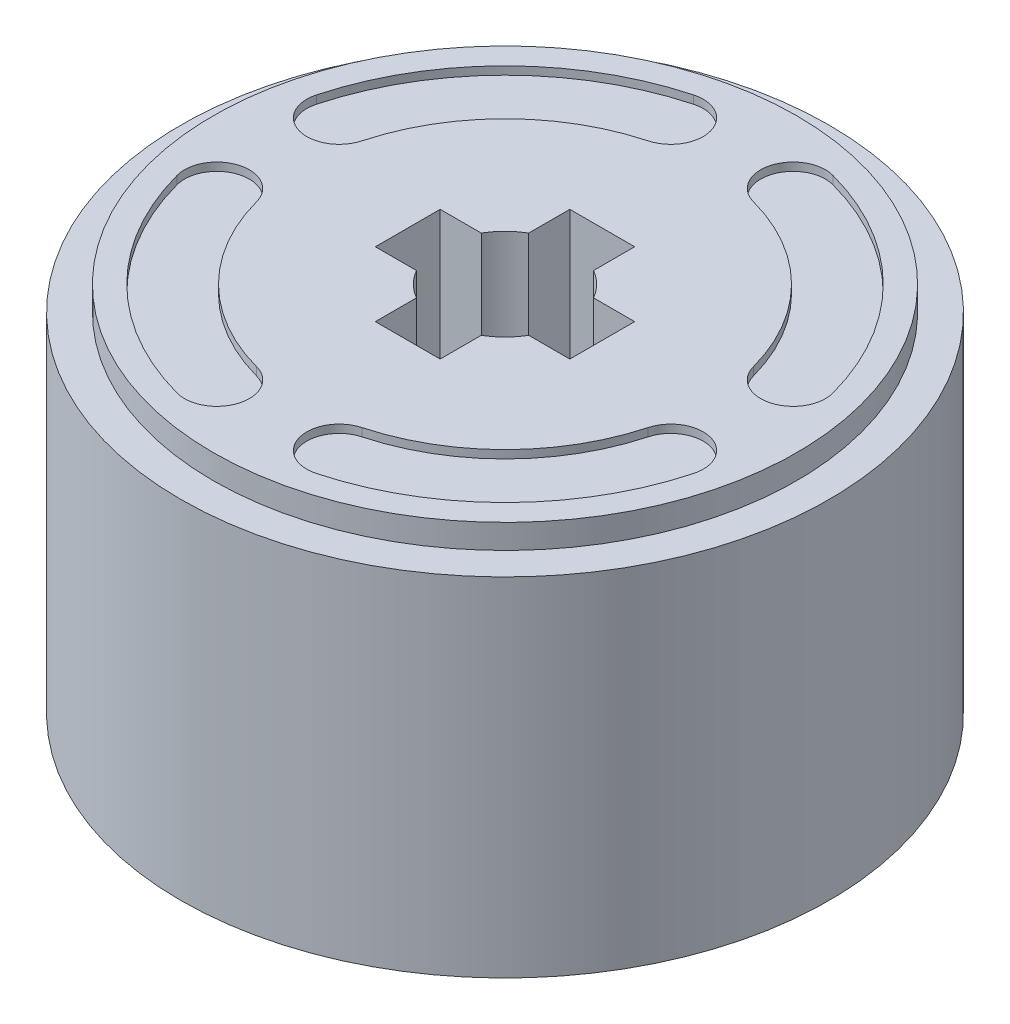
from build123d import *

# Parameters (mm, degrees)
SKETCH1_R           = 14
BOSS_EXTRUDE2_DEPTH = 16.05
CUT_EXTRUDE1_START  = -1.05
SKETCH3_R           = 14
SKETCH3_R_2         = 12.6
CUT_EXTRUDE1_DEPTH  = 1.05
CUT_EXTRUDE2_DEPTH  = 0.35


with BuildPart() as part:
    # Sketch1 → Boss-Extrude2 (new body)
    with BuildSketch(Plane(origin=(0, 0, 0), x_dir=(1, 0, 0), z_dir=(0, 1, 0))):
        Circle(SKETCH1_R)
        with BuildLine():
            Line((-1.4, 4.2), (-1.4, 2.424871131))
            ThreePointArc((-1.4, 2.424871131), (-1.979898987, 1.979898987), (-2.424871131, 1.4))
            Line((-2.424871131, 1.4), (-4.2, 1.4))
            Line((-4.2, 1.4), (-4.2, -1.4))
            Line((-4.2, -1.4), (-2.424871131, -1.4))
            ThreePointArc((-2.424871131, -1.4), (-1.979898987, -1.979898987), (-1.4, -2.424871131))
            Line((-1.4, -2.424871131), (-1.4, -4.2))
            Line((-1.4, -4.2), (1.4, -4.2))
            Line((1.4, -4.2), (1.4, -2.424871131))
            ThreePointArc((1.4, -2.424871131), (1.979898987, -1.979898987), (2.424871131, -1.4))
            Line((2.424871131, -1.4), (4.2, -1.4))
            Line((4.2, -1.4), (4.2, 1.4))
            Line((4.2, 1.4), (2.424871131, 1.4))
            ThreePointArc((2.424871131, 1.4), (1.979898987, 1.979898987), (1.4, 2.424871131))
            Line((1.4, 2.424871131), (1.4, 4.2))
            Line((1.4, 4.2), (-1.4, 4.2))
        make_face(mode=Mode.SUBTRACT)
    extrude(amount=BOSS_EXTRUDE2_DEPTH)

    # Sketch3 → Cut-Extrude1 (cut)
    with BuildSketch(Plane(origin=(0, 16.05, 0), x_dir=(1, 0, 0), z_dir=(0, 1, 0)).offset(CUT_EXTRUDE1_START)):
        Circle(SKETCH3_R)
        Circle(SKETCH3_R_2, mode=Mode.SUBTRACT)
    extrude(amount=CUT_EXTRUDE1_DEPTH, mode=Mode.SUBTRACT)

    # Sketch3_3 → Cut-Extrude2 (cut)
    with BuildSketch(Plane(origin=(0, 16.05, 0), x_dir=(1, 0, 0), z_dir=(0, 1, 0))):
        with BuildLine():
            ThreePointArc((8.448706113, 2.27637102), (10.164718454, 1.288797405), (11.152292069, 3.004809746))
            ThreePointArc((11.152292069, 3.004809746), (8.167083323, 8.167083323), (3.004809746, 11.152292069))
            ThreePointArc((3.004809746, 11.152292069), (1.288797405, 10.164718454), (2.27637102, 8.448706113))
            ThreePointArc((2.27637102, 8.448706113), (6.187184335, 6.187184335), (8.448706113, 2.27637102))
        make_face()
        with BuildLine():
            ThreePointArc((2.27637102, -8.448706113), (1.288797405, -10.164718454), (3.004809746, -11.152292069))
            ThreePointArc((3.004809746, -11.152292069), (8.167083323, -8.167083323), (11.152292069, -3.004809746))
            ThreePointArc((11.152292069, -3.004809746), (10.164718454, -1.288797405), (8.448706113, -2.27637102))
            ThreePointArc((8.448706113, -2.27637102), (6.187184335, -6.187184335), (2.27637102, -8.448706113))
        make_face()
        with BuildLine():
            ThreePointArc((-8.448706113, -2.27637102), (-10.164718454, -1.288797405), (-11.152292069, -3.004809746))
            ThreePointArc((-11.152292069, -3.004809746), (-8.167083323, -8.167083323), (-3.004809746, -11.152292069))
            ThreePointArc((-3.004809746, -11.152292069), (-1.288797405, -10.164718454), (-2.27637102, -8.448706113))
            ThreePointArc((-2.27637102, -8.448706113), (-6.187184335, -6.187184335), (-8.448706113, -2.27637102))
        make_face()
        with BuildLine():
            ThreePointArc((-2.27637102, 8.448706113), (-1.288797405, 10.164718454), (-3.004809746, 11.152292069))
            ThreePointArc((-3.004809746, 11.152292069), (-8.167083323, 8.167083323), (-11.152292069, 3.004809746))
            ThreePointArc((-11.152292069, 3.004809746), (-10.164718454, 1.288797405), (-8.448706113, 2.27637102))
            ThreePointArc((-8.448706113, 2.27637102), (-6.187184335, 6.187184335), (-2.27637102, 8.448706113))
        make_face()
    extrude(amount=-CUT_EXTRUDE2_DEPTH, mode=Mode.SUBTRACT)


solid = part.part
